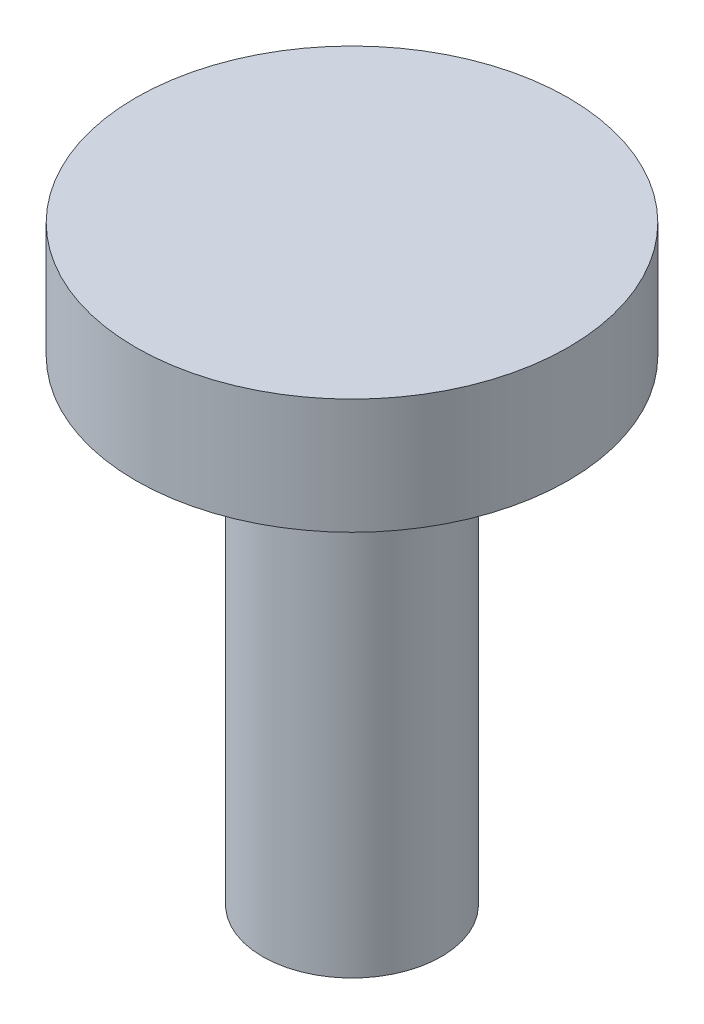
from build123d import *

# Parameters (mm, degrees)
SKETCH_1_R      = 3.1
EXTRUDE_1_DEPTH = 16.5
SKETCH_2_R      = 7.5
EXTRUDE_2_DEPTH = 4


with BuildPart() as part:
    # Эскиз1 → Бобышка-Вытянуть1 (new body)
    with BuildSketch(Plane(origin=(0, 0, 0), x_dir=(1, 0, 0), z_dir=(0, 1, 0))):
        Circle(SKETCH_1_R)
    extrude(amount=EXTRUDE_1_DEPTH)

    # Эскиз2 → Бобышка-Вытянуть2 (add)
    with BuildSketch(Plane(origin=(0, 16.5, 0), x_dir=(1, 0, 0), z_dir=(0, 1, 0))):
        Circle(SKETCH_2_R)
    extrude(amount=EXTRUDE_2_DEPTH)


solid = part.part
